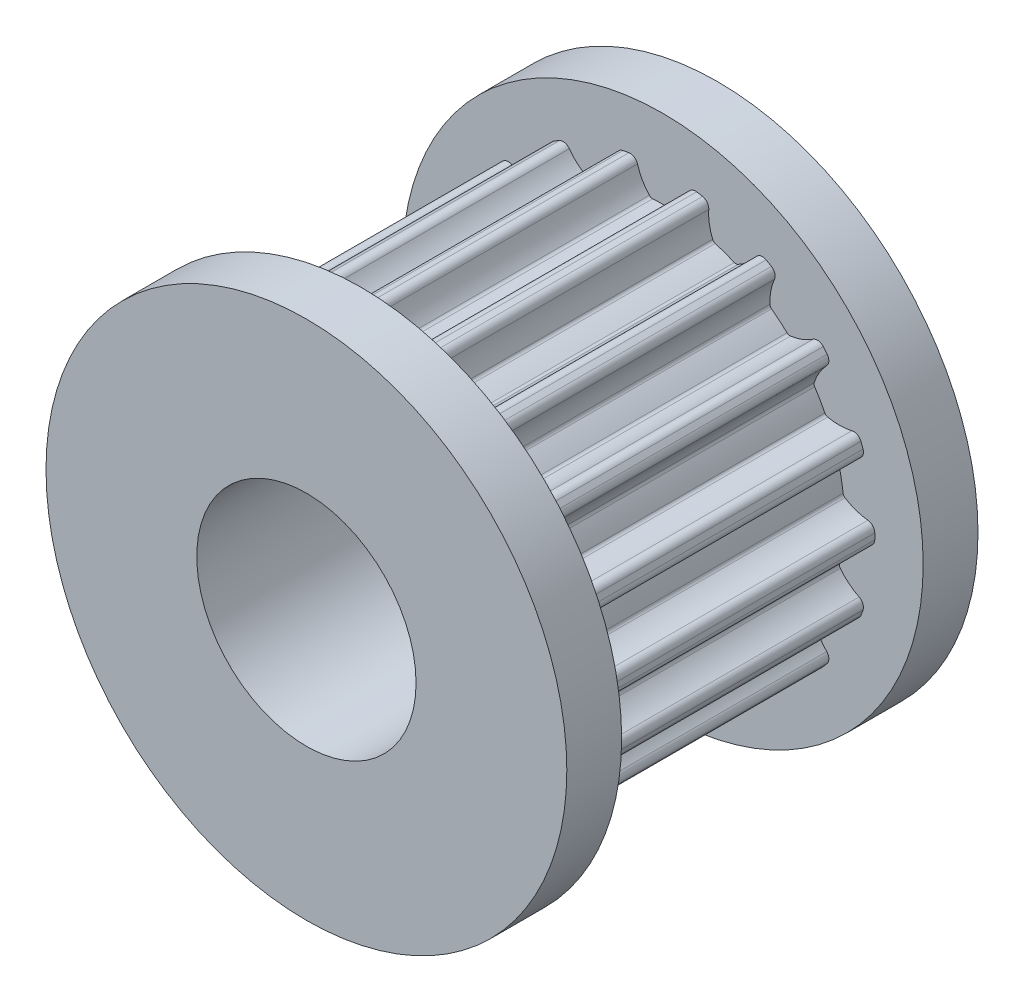
from build123d import *

# Parameters (mm, degrees)
SKETCH_1_R               = 7.735
EXTRUDE_1_DEPTH          = 5.5
CUT_EXTRUDE_START        = -12
CUT_EXTRUDE_1_DEPTH      = 13
PATTERN_CIRCULAR_1_COUNT = 18
SKETCH_3_R               = 9.5
EXTRUDE_2_DEPTH          = 2
SKETCH_9_R               = 9.5
EXTRUDE_3_DEPTH          = 2
SKETCH_4_R               = 4
CUT_EXTRUDE_2_DEPTH      = 16
SKETCH_10_R              = 2
CUT_EXTRUDE_3_DEPTH      = 10.5
SKETCH_11_R              = 2
CUT_EXTRUDE_4_DEPTH      = 10.5


with BuildPart() as part:
    # 草圖1 → 填料-伸長1 (new body, symmetric)
    with BuildSketch(Plane.XY):
        Circle(SKETCH_1_R)
    extrude(amount=EXTRUDE_1_DEPTH, both=True)

    # 草圖2 → 除料-伸長1 (cut)
    with BuildSketch(Plane.XY.offset(5.5).offset(CUT_EXTRUDE_START)):
        with BuildLine():
            ThreePointArc((-0.369797999, 6.614671151), (0, 6.625), (0.369797999, 6.614671151))
            ThreePointArc((0.369797999, 6.614671151), (0.435157503, 6.625683862), (0.4893903, 6.663788301))
            ThreePointArc((0.4893903, 6.663788301), (0.749379197, 7.026118188), (0.921448937, 7.437541543))
            ThreePointArc((0.921448937, 7.437541543), (1.040696313, 7.596034914), (1.23501916, 7.635767982))
            ThreePointArc((1.23501916, 7.635767982), (0, 7.735), (-1.23501916, 7.635767982))
            ThreePointArc((-1.23501916, 7.635767982), (-1.040696313, 7.596034914), (-0.921448937, 7.437541543))
            ThreePointArc((-0.921448937, 7.437541543), (-0.749379197, 7.026118188), (-0.4893903, 6.663788301))
            ThreePointArc((-0.4893903, 6.663788301), (-0.435157503, 6.625683862), (-0.369797999, 6.614671151))
        make_face()
    cut_extrude_1 = extrude(amount=CUT_EXTRUDE_1_DEPTH, mode=Mode.SUBTRACT)

    # 環狀複製排列1: 除料-伸長1 ×18 about axis
    pattern_circular_1_axis = Axis((0, 0, 0), (0, 0, 1))
    for i in range(1, PATTERN_CIRCULAR_1_COUNT):
        add(cut_extrude_1.rotate(pattern_circular_1_axis, i * 360 / PATTERN_CIRCULAR_1_COUNT), mode=Mode.SUBTRACT)

    # 草圖3 → 填料-伸長2 (add)
    with BuildSketch(Plane.XY.offset(5.5)):
        Circle(SKETCH_3_R)
    extrude(amount=EXTRUDE_2_DEPTH)

    # 草圖9 → 填料-伸長3 (add)
    with BuildSketch(Plane(origin=(0, 0, -5.5), x_dir=(-1, 0, 0), z_dir=(0, 0, -1))):
        Circle(SKETCH_9_R)
    extrude(amount=EXTRUDE_3_DEPTH)

    # 草圖4 → 除料-伸長2 (cut, through all)
    with BuildSketch(Plane.XY.offset(7.5)):
        Circle(SKETCH_4_R)
    extrude(amount=-CUT_EXTRUDE_2_DEPTH, mode=Mode.SUBTRACT)

    # 草圖10 → 除料-伸長3 (cut, through all)
    with BuildSketch(Plane(origin=(0, 0, 0), x_dir=(1, 0, 0), z_dir=(0, 1, 0))):
        Circle(SKETCH_10_R)
    extrude(amount=-CUT_EXTRUDE_3_DEPTH, mode=Mode.SUBTRACT)

    # 草圖11 → 除料-伸長4 (cut, through all)
    with BuildSketch(Plane(origin=(0, 0, 0), x_dir=(0, 0, -1), z_dir=(1, 0, 0))):
        Circle(SKETCH_11_R)
    extrude(amount=-CUT_EXTRUDE_4_DEPTH, mode=Mode.SUBTRACT)


solid = part.part
